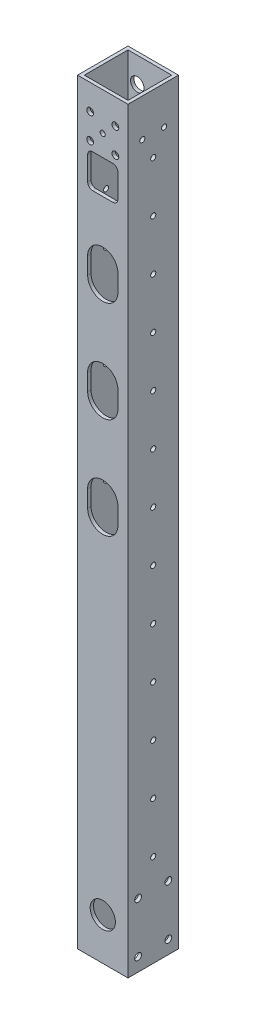
from build123d import *

# Parameters (mm, degrees)
SKETCH_2_W                = 30
SKETCH_2_H                = 30
EXTRUDE_1_DEPTH           = 225
SKETCH_4_W                = 26
SKETCH_4_H                = 26
CUT_EXTRUDE_1_DEPTH       = 226
CUT_EXTRUDE_1_DEPTH_BACK  = 226
SKETCH_5_R                = 2.025
CUT_EXTRUDE_2_DEPTH       = 1
CUT_EXTRUDE_2_DEPTH_BACK  = 31
CUT_EXTRUDE_3_DEPTH       = 10
CUT_EXTRUDE_START         = -31
SKETCH_8_R                = 1.525
CUT_EXTRUDE_4_DEPTH       = 32
PATTERN_LINEAR_2_COUNT    = 13
PATTERN_LINEAR_2_PITCH    = 30
PATTERN_LINEAR_3_COUNT    = 7
PATTERN_LINEAR_3_PITCH    = 57
SKETCH_9_R                = 1.525
CUT_EXTRUDE_5_DEPTH       = 1
CUT_EXTRUDE_5_DEPTH_BACK  = 31
SKETCH_10_R               = 2.025
CUT_EXTRUDE_6_DEPTH       = 1
CUT_EXTRUDE_6_DEPTH_BACK  = 31
SKETCH_6_R                = 4
CUT_EXTRUDE_7_DEPTH       = 10
CUT_EXTRUDE_8_DEPTH       = 10
CUT_EXTRUDE_9_DEPTH       = 10
SKETCH_13_R               = 1.525
CUT_EXTRUDE_10_DEPTH      = 1
CUT_EXTRUDE_10_DEPTH_BACK = 31
SKETCH_14_R               = 7.5
CUT_EXTRUDE_11_DEPTH      = 2


with BuildPart() as part:
    # 草图2 → 凸台-拉伸1 (new body, symmetric)
    with BuildSketch(Plane(origin=(0, 0, 0), x_dir=(1, 0, 0), z_dir=(0, 1, 0))):
        Rectangle(SKETCH_2_W, SKETCH_2_H)
    extrude(amount=EXTRUDE_1_DEPTH, both=True)

    # 草图4 → 切除-拉伸1 (cut, two sides)
    with BuildSketch(Plane(origin=(0, 0, 0), x_dir=(1, 0, 0), z_dir=(0, 1, 0))) as cut_extrude_1_sk:
        Rectangle(SKETCH_4_W, SKETCH_4_H)
    extrude(amount=CUT_EXTRUDE_1_DEPTH, mode=Mode.SUBTRACT)
    extrude(cut_extrude_1_sk.sketch, amount=-CUT_EXTRUDE_1_DEPTH_BACK, mode=Mode.SUBTRACT)

    # 草图5 → 切除-拉伸2 (cut, two sides)
    with BuildSketch(Plane(origin=(0, 0, -15), x_dir=(-1, 0, 0), z_dir=(0, 0, -1))) as cut_extrude_2_sk:
        with Locations((-7.5, 210)):
            Circle(SKETCH_5_R)
        with Locations((7.5, 210)):
            Circle(SKETCH_5_R)
        with Locations((-7.5, 195)):
            Circle(SKETCH_5_R)
        with Locations((7.5, 195)):
            Circle(SKETCH_5_R)
    extrude(amount=CUT_EXTRUDE_2_DEPTH, mode=Mode.SUBTRACT)
    extrude(cut_extrude_2_sk.sketch, amount=-CUT_EXTRUDE_2_DEPTH_BACK, mode=Mode.SUBTRACT)

    # 草图7 → 切除-拉伸3 (cut)
    with BuildSketch(Plane(origin=(0, 0, -15), x_dir=(-1, 0, 0), z_dir=(0, 0, -1))):
        with BuildLine():
            Line((-9, -196.5), (-9, -165.5))
            ThreePointArc((-9, -165.5), (0, -156.5), (9, -165.5))
            Line((9, -165.5), (9, -196.5))
            ThreePointArc((9, -196.5), (0, -205.5), (-9, -196.5))
        make_face()
    cut_extrude_3 = extrude(amount=-CUT_EXTRUDE_3_DEPTH, mode=Mode.SUBTRACT)

    # 草图8 → 切除-拉伸4 (cut)
    with BuildSketch(Plane(origin=(15, 0, 0), x_dir=(0, 0, -1), z_dir=(1, 0, 0)).offset(CUT_EXTRUDE_START)):
        with Locations((0, -170.000000001)):
            Circle(SKETCH_8_R)
    cut_extrude_4 = extrude(amount=CUT_EXTRUDE_4_DEPTH, mode=Mode.SUBTRACT)

    # 阵列(线性)2: 切除-拉伸4 ×13
    with Locations(*[(0, i * PATTERN_LINEAR_2_PITCH, 0) for i in range(1, PATTERN_LINEAR_2_COUNT)]):
        add(cut_extrude_4, mode=Mode.SUBTRACT)

    # 阵列(线性)3: 切除-拉伸3 ×7
    with Locations(*[(0, i * PATTERN_LINEAR_3_PITCH, 0) for i in range(1, PATTERN_LINEAR_3_COUNT)]):
        add(cut_extrude_3, mode=Mode.SUBTRACT)

    # 草图9 → 切除-拉伸5 (cut, two sides)
    with BuildSketch(Plane(origin=(15, 0, 0), x_dir=(0, 0, -1), z_dir=(1, 0, 0))) as cut_extrude_5_sk:
        with Locations((6.5, 202.5)):
            Circle(SKETCH_9_R)
        with Locations((-6.5, 202.5)):
            Circle(SKETCH_9_R)
    extrude(amount=CUT_EXTRUDE_5_DEPTH, mode=Mode.SUBTRACT)
    extrude(cut_extrude_5_sk.sketch, amount=-CUT_EXTRUDE_5_DEPTH_BACK, mode=Mode.SUBTRACT)

    # 草图10 → 切除-拉伸6 (cut, two sides)
    with BuildSketch(Plane(origin=(15, 0, 0), x_dir=(0, 0, -1), z_dir=(1, 0, 0))) as cut_extrude_6_sk:
        with Locations((9, -187)):
            Circle(SKETCH_10_R)
        with Locations((-9, -187)):
            Circle(SKETCH_10_R)
        with Locations((-9, -217)):
            Circle(SKETCH_10_R)
        with Locations((9, -217)):
            Circle(SKETCH_10_R)
    extrude(amount=CUT_EXTRUDE_6_DEPTH, mode=Mode.SUBTRACT)
    extrude(cut_extrude_6_sk.sketch, amount=-CUT_EXTRUDE_6_DEPTH_BACK, mode=Mode.SUBTRACT)

    # 草图6 → 切除-拉伸7 (cut)
    with BuildSketch(Plane(origin=(0, 0, -15), x_dir=(-1, 0, 0), z_dir=(0, 0, -1))):
        with Locations((-7.5, 210)):
            Circle(SKETCH_6_R)
        with Locations((-7.5, 195)):
            Circle(SKETCH_6_R)
        with Locations((7.5, 195)):
            Circle(SKETCH_6_R)
        with Locations((7.5, 210)):
            Circle(SKETCH_6_R)
    extrude(amount=-CUT_EXTRUDE_7_DEPTH, mode=Mode.SUBTRACT)

    # 草图11 → 切除-拉伸8 (cut)
    with BuildSketch(Plane.XY.offset(15)):
        with BuildLine():
            Line((-9, 125), (-9, 135))
            ThreePointArc((-9, 135), (0, 144), (9, 135))
            Line((9, 135), (9, 125))
            ThreePointArc((9, 125), (0, 116), (-9, 125))
        make_face()
        with BuildLine():
            Line((-9, 65), (-9, 75))
            ThreePointArc((-9, 75), (0, 84), (9, 75))
            Line((9, 75), (9, 65))
            ThreePointArc((9, 65), (0, 56), (-9, 65))
        make_face()
        with BuildLine():
            Line((-9, 5), (-9, 15))
            ThreePointArc((-9, 15), (0, 24), (9, 15))
            Line((9, 15), (9, 5))
            ThreePointArc((9, 5), (0, -4), (-9, 5))
        make_face()
    extrude(amount=-CUT_EXTRUDE_8_DEPTH, mode=Mode.SUBTRACT)

    # 草图12 → 切除-拉伸9 (cut)
    with BuildSketch(Plane.XY.offset(15)):
        with BuildLine():
            Line((-6, 170), (6, 170))
            ThreePointArc((6, 170), (8.121320344, 170.878679656), (9, 173))
            Line((9, 173), (9, 187))
            ThreePointArc((9, 187), (8.121320344, 189.121320344), (6, 190))
            Line((6, 190), (-6, 190))
            ThreePointArc((-6, 190), (-8.121320344, 189.121320344), (-9, 187))
            Line((-9, 187), (-9, 173))
            ThreePointArc((-9, 173), (-8.121320344, 170.878679656), (-6, 170))
        make_face()
    extrude(amount=-CUT_EXTRUDE_9_DEPTH, mode=Mode.SUBTRACT)

    # 草图13 → 切除-拉伸10 (cut, two sides)
    with BuildSketch(Plane(origin=(0, 0, -15), x_dir=(-1, 0, 0), z_dir=(0, 0, -1))) as cut_extrude_10_sk:
        with Locations((0.05, 202.5)):
            Circle(SKETCH_13_R)
    extrude(amount=CUT_EXTRUDE_10_DEPTH, mode=Mode.SUBTRACT)
    extrude(cut_extrude_10_sk.sketch, amount=-CUT_EXTRUDE_10_DEPTH_BACK, mode=Mode.SUBTRACT)

    # 草图14 → 切除-拉伸11 (cut)
    with BuildSketch(Plane(origin=(0, 0, 13), x_dir=(-1, 0, 0), z_dir=(0, 0, -1))):
        with Locations((0, -200)):
            Circle(SKETCH_14_R)
    extrude(amount=-CUT_EXTRUDE_11_DEPTH, mode=Mode.SUBTRACT)


solid = part.part
